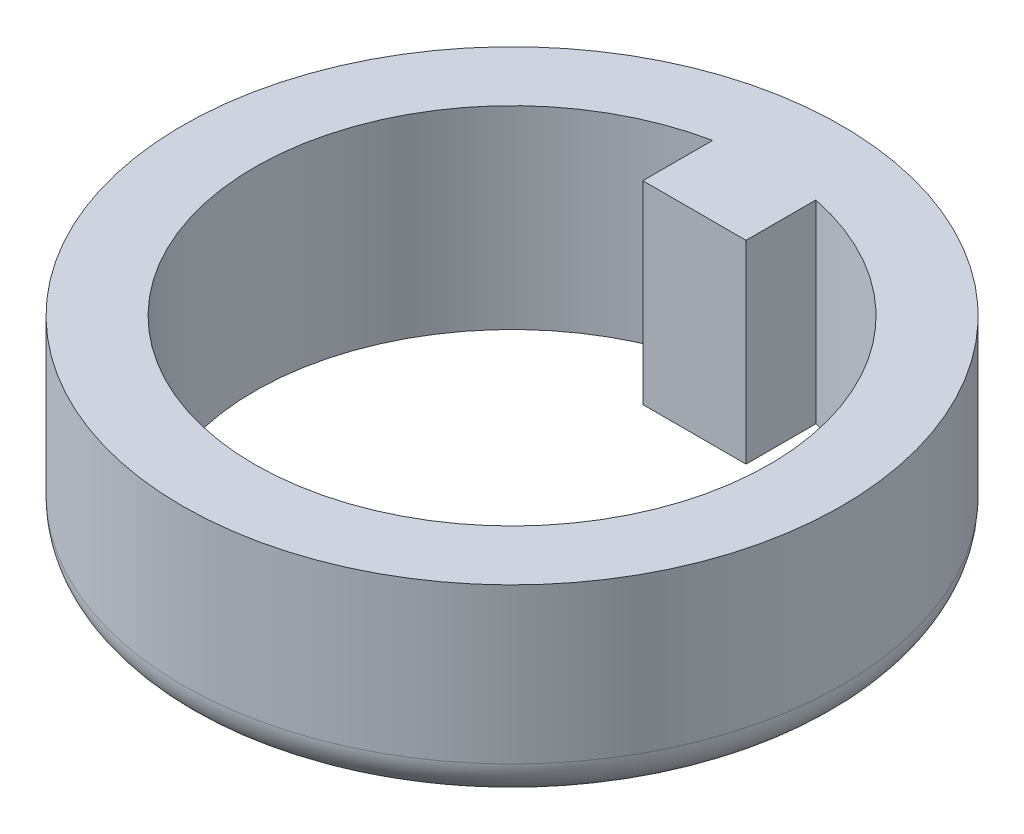
from build123d import *

# Parameters (mm, degrees)
SKETCH1_R           = 8.5
BOSS_EXTRUDE1_DEPTH = 5
FILLET3_R           = 1


with BuildPart() as part:
    # Sketch1 → Boss-Extrude1 (new body)
    with BuildSketch(Plane(origin=(0, 0, 0), x_dir=(1, 0, 0), z_dir=(0, 1, 0))):
        Circle(SKETCH1_R)
        with BuildLine():
            Line((-1.332, 6.504006227), (-1.332, 4.704006227))
            Line((-1.332, 4.704006227), (1.33, 4.704006227))
            Line((1.33, 4.704006227), (1.33, 6.5044155))
            ThreePointArc((1.33, 6.5044155), (0.001020723, -6.638999922), (-1.332, 6.504006227))
        make_face(mode=Mode.SUBTRACT)
    extrude(amount=BOSS_EXTRUDE1_DEPTH)

    # Fillet3
    fillet3_edges = [part.edges().sort_by_distance(p)[0] for p in [
        (-8.5, 0, 0),
    ]]
    fillet(fillet3_edges, radius=FILLET3_R)


solid = part.part
